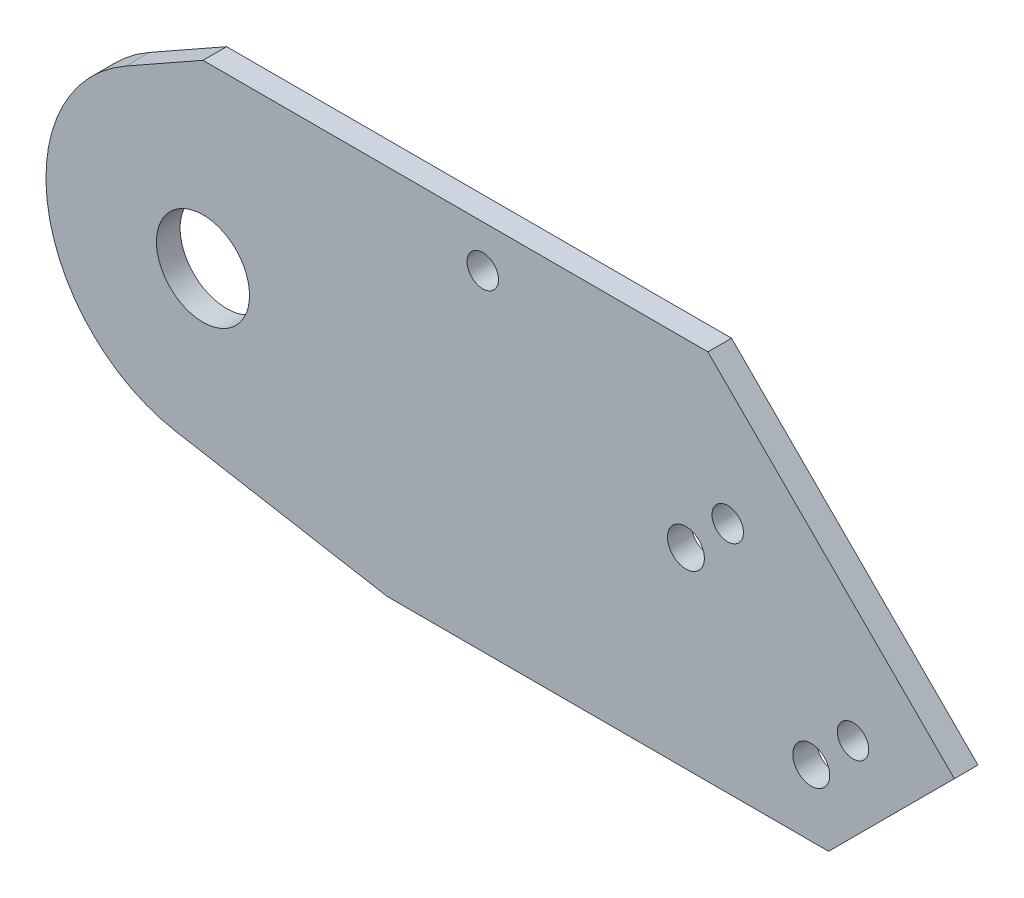
from build123d import *

# Parameters (mm, degrees)
SKETCH2_R           = 4
SKETCH2_R_2         = 1.35255
BOSS_EXTRUDE1_DEPTH = 2.032
SKETCH5_R           = 1.5875
SKETCH5_R_2         = 1.35255
CUT_EXTRUDE1_DEPTH  = 67.699232753


with BuildPart() as part:
    # Sketch2 → Boss-Extrude1 (new body)
    with BuildSketch(Plane.XY):
        with BuildLine():
            Line((64.594184148, -5.687884281), (43.406299867, 15.5))
            Line((43.406299867, 15.5), (0, 15.5))
            Line((0, 15.5), (-6.633092705, 11.758064516))
            ThreePointArc((-6.633092705, 11.758064516), (-13.306426587, -2.277940187), (-2.344250399, -13.294904666))
            Line((-2.344250399, -13.294904666), (15.832748501, -16.5))
            Line((15.832748501, -16.5), (53.78206843, -16.5))
            Line((53.78206843, -16.5), (64.594184148, -5.687884281))
        make_face()
        Circle(SKETCH2_R, mode=Mode.SUBTRACT)
        with Locations((24.053244616, 11.867587507)):
            Circle(SKETCH2_R_2, mode=Mode.SUBTRACT)
    extrude(amount=BOSS_EXTRUDE1_DEPTH)

    # Sketch5 → Cut-Extrude1 (cut, through all)
    with BuildSketch(Plane(origin=(0, 0, 0), x_dir=(-1, 0, 0), z_dir=(0, 0, -1))):
        with Locations((-41.514925917, -0.030322925)):
            Circle(SKETCH5_R)
        with Locations((-52.291233263, -10.80663027)):
            Circle(SKETCH5_R)
        with Locations((-45.107028366, 3.561779523)):
            Circle(SKETCH5_R_2)
        with Locations((-55.883335711, -7.214527822)):
            Circle(SKETCH5_R_2)
    extrude(amount=-CUT_EXTRUDE1_DEPTH, mode=Mode.SUBTRACT)


solid = part.part
